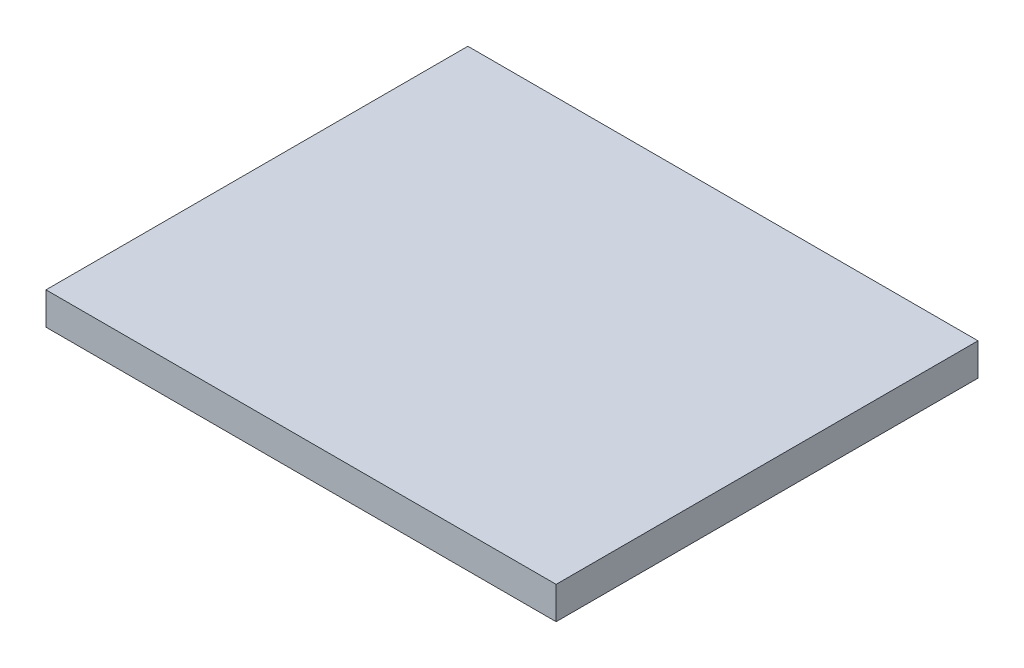
from build123d import *

# Parameters (mm, degrees)
SKETCH1_W           = 50
SKETCH1_H           = 41.35
BOSS_EXTRUDE1_DEPTH = 3.175


with BuildPart() as part:
    # Sketch1 → Boss-Extrude1 (new body)
    with BuildSketch(Plane(origin=(0, 0, 0), x_dir=(1, 0, 0), z_dir=(0, 1, 0))):
        Rectangle(SKETCH1_W, SKETCH1_H)
    extrude(amount=BOSS_EXTRUDE1_DEPTH)


solid = part.part
